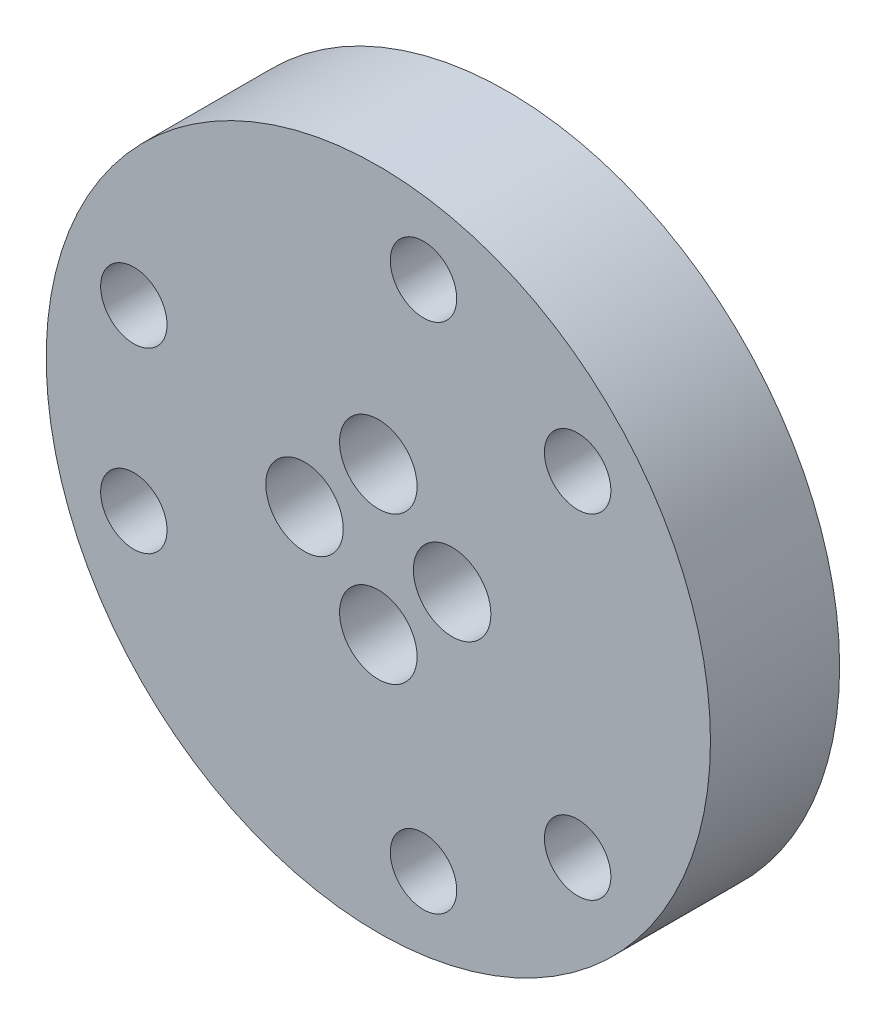
from build123d import *

# Parameters (mm, degrees)
SKETCH_1_R                   = 18
SKETCH_1_R_2                 = 1.1
SKETCH_1_R_3                 = 1.6
EXTRUDE_1_DEPTH              = 7
SKETCH_5_R                   = 2.1
CUT_EXTRUDE_1_DEPTH          = 5.6
HOLE_WIZARD_M3_2_D           = 3.6
HOLE_WIZARD_M3_2_CSINK_D     = 6.3
HOLE_WIZARD_M3_2_CSINK_ANGLE = 90


with BuildPart() as part:
    # 스케치1 → 보스-돌출1 (new body)
    with BuildSketch(Plane.XY):
        Circle(SKETCH_1_R)
        with Locations((0, 4)):
            Circle(SKETCH_1_R_2, mode=Mode.SUBTRACT)
        with Locations((4, 0)):
            Circle(SKETCH_1_R_2, mode=Mode.SUBTRACT)
        with Locations((0, -4)):
            Circle(SKETCH_1_R_2, mode=Mode.SUBTRACT)
        with Locations((-4, 0)):
            Circle(SKETCH_1_R_2, mode=Mode.SUBTRACT)
        with Locations((-13.249665953, 4.822484021)):
            Circle(SKETCH_1_R_3, mode=Mode.SUBTRACT)
        with Locations((-13.249665953, -4.822484021)):
            Circle(SKETCH_1_R_3, mode=Mode.SUBTRACT)
        with Locations((10.801226648, 9.063305297)):
            Circle(SKETCH_1_R_3, mode=Mode.SUBTRACT)
        with Locations((2.448439305, 13.885789317)):
            Circle(SKETCH_1_R_3, mode=Mode.SUBTRACT)
        with Locations((2.448439305, -13.885789317)):
            Circle(SKETCH_1_R_3, mode=Mode.SUBTRACT)
        with Locations((10.801226648, -9.063305297)):
            Circle(SKETCH_1_R_3, mode=Mode.SUBTRACT)
    extrude(amount=EXTRUDE_1_DEPTH)

    # 스케치5 → 컷-돌출1 (cut)
    with BuildSketch(Plane.XY.offset(7)):
        with Locations((0, 4)):
            Circle(SKETCH_5_R)
        with Locations((0, -4)):
            Circle(SKETCH_5_R)
        with Locations((4, 0)):
            Circle(SKETCH_5_R)
        with Locations((-4, 0)):
            Circle(SKETCH_5_R)
    extrude(amount=-CUT_EXTRUDE_1_DEPTH, mode=Mode.SUBTRACT)

    # M3 접시 머리 나사용 카운터싱크2 (through all)
    with Locations(Plane(origin=(0, 0, 0), x_dir=(-1, 0, 0), z_dir=(0, 0, -1))):
        with Locations((-2.448439305, 13.885789317), (13.249665953, 4.822484021), (13.249665953, -4.822484021), (-2.448439305, -13.885789317), (-10.801226648, -9.063305297), (-10.801226648, 9.063305297)):
            CounterSinkHole(HOLE_WIZARD_M3_2_D / 2, HOLE_WIZARD_M3_2_CSINK_D / 2, counter_sink_angle=HOLE_WIZARD_M3_2_CSINK_ANGLE)


solid = part.part
